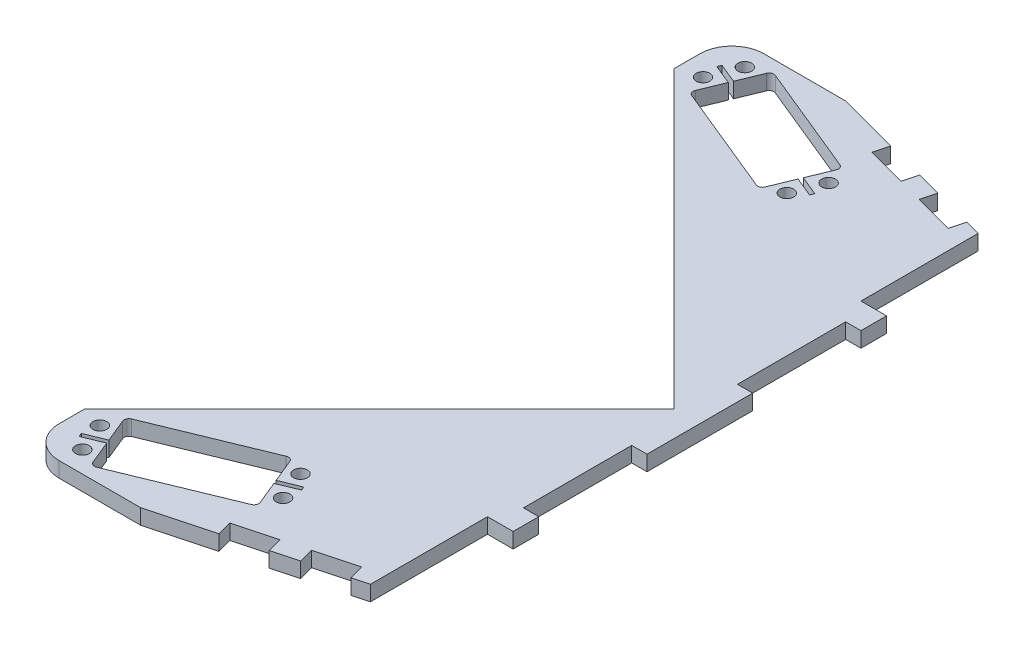
from build123d import *

# Parameters (mm, degrees)
SKETCH1_R           = 2.15
BOSS_EXTRUDE1_DEPTH = 4.7625
FILLET1_R           = 10
SKETCH2_W           = 4.7625
SKETCH2_H           = 33.783
CUT_EXTRUDE1_DEPTH  = 10


with BuildPart() as part:
    # Sketch1 → Boss-Extrude1 (new body)
    with BuildSketch(Plane(origin=(0, 0, 0), x_dir=(1, 0, 0), z_dir=(0, 1, 0))):
        Polygon((0, 0), (-92, 92), (-92, 110), (-56.601944845, 110), (0, 94.833554589), (0, 58.293), (8, 58.293), (8, -58.293), (0, -58.293), (0, -94.833554589), (-56.601944845, -110), (-92, -110), (-92, -92), align=None)
        with Locations((-85.159917522, 94.147890435)):
            Circle(SKETCH1_R, mode=Mode.SUBTRACT)
        with Locations((-81.358825255, 103.397306502)):
            Circle(SKETCH1_R, mode=Mode.SUBTRACT)
        with Locations((-36.961628134, 85.152063619)):
            Circle(SKETCH1_R, mode=Mode.SUBTRACT)
        with Locations((-40.762720402, 75.902647552)):
            Circle(SKETCH1_R, mode=Mode.SUBTRACT)
        with Locations((-40.762720402, -75.902647552)):
            Circle(SKETCH1_R, mode=Mode.SUBTRACT)
        with Locations((-36.961628134, -85.152063619)):
            Circle(SKETCH1_R, mode=Mode.SUBTRACT)
        with Locations((-81.358825255, -103.397306502)):
            Circle(SKETCH1_R, mode=Mode.SUBTRACT)
        with Locations((-85.159917522, -94.147890435)):
            Circle(SKETCH1_R, mode=Mode.SUBTRACT)
        with BuildLine():
            Line((-79.322036695, 97.830250065), (-76.328676535, 105.114165218))
            ThreePointArc((-76.328676535, 105.114165218), (-76.087243425, 105.511850251), (-75.735570504, 105.816431091))
            ThreePointArc((-75.735570504, 105.816431091), (-75.067221358, 106.038703614), (-74.371100284, 105.931413788))
            Line((-74.371100284, 105.931413788), (-40.148260837, 91.867372399))
            ThreePointArc((-40.148260837, 91.867372399), (-39.577853455, 91.454176231), (-39.258927152, 90.826178087))
            ThreePointArc((-39.258927152, 90.826178087), (-39.223044121, 90.362329254), (-39.331012268, 89.909796149))
            Line((-39.331012268, 89.909796149), (-42.324372428, 82.625880996))
            Line((-42.324372428, 82.625880996), (-36.219757824, 80.1171601))
            Line((-36.219757824, 80.1171601), (-36.694894357, 78.960983092))
            Line((-36.694894357, 78.960983092), (-42.799508961, 81.469703988))
            Line((-42.799508961, 81.469703988), (-45.792869122, 74.185788836))
            ThreePointArc((-45.792869122, 74.185788836), (-46.034302231, 73.788103802), (-46.385975153, 73.483522962))
            ThreePointArc((-46.385975153, 73.483522962), (-47.054324299, 73.261250439), (-47.750445372, 73.368540266))
            Line((-47.750445372, 73.368540266), (-81.973284819, 87.432581654))
            ThreePointArc((-81.973284819, 87.432581654), (-82.543692202, 87.845777823), (-82.862618505, 88.473775966))
            ThreePointArc((-82.862618505, 88.473775966), (-82.898501536, 88.937624799), (-82.790533389, 89.390157905))
            Line((-82.790533389, 89.390157905), (-79.797173228, 96.674073057))
            Line((-79.797173228, 96.674073057), (-85.901787832, 99.182793954))
            Line((-85.901787832, 99.182793954), (-85.426651299, 100.338970962))
            Line((-85.426651299, 100.338970962), (-79.322036695, 97.830250065))
        make_face(mode=Mode.SUBTRACT)
        with BuildLine():
            Line((-47.750445372, -73.368540266), (-81.973284819, -87.432581654))
            ThreePointArc((-81.973284819, -87.432581654), (-82.543692202, -87.845777823), (-82.862618505, -88.473775966))
            ThreePointArc((-82.862618505, -88.473775966), (-82.898501536, -88.937624799), (-82.790533389, -89.390157905))
            Line((-82.790533389, -89.390157905), (-79.797173228, -96.674073057))
            Line((-79.797173228, -96.674073057), (-85.901787832, -99.182793954))
            Line((-85.901787832, -99.182793954), (-85.426651299, -100.338970962))
            Line((-85.426651299, -100.338970962), (-79.322036695, -97.830250065))
            Line((-79.322036695, -97.830250065), (-76.328676535, -105.114165218))
            ThreePointArc((-76.328676535, -105.114165218), (-76.087243425, -105.511850251), (-75.735570504, -105.816431091))
            ThreePointArc((-75.735570504, -105.816431091), (-75.067221358, -106.038703614), (-74.371100284, -105.931413788))
            Line((-74.371100284, -105.931413788), (-40.148260837, -91.867372399))
            ThreePointArc((-40.148260837, -91.867372399), (-39.577853455, -91.454176231), (-39.258927152, -90.826178087))
            ThreePointArc((-39.258927152, -90.826178087), (-39.223044121, -90.362329254), (-39.331012268, -89.909796149))
            Line((-39.331012268, -89.909796149), (-42.324372428, -82.625880996))
            Line((-42.324372428, -82.625880996), (-36.219757824, -80.1171601))
            Line((-36.219757824, -80.1171601), (-36.694894357, -78.960983092))
            Line((-36.694894357, -78.960983092), (-42.799508961, -81.469703988))
            Line((-42.799508961, -81.469703988), (-45.792869122, -74.185788836))
            ThreePointArc((-45.792869122, -74.185788836), (-46.034302231, -73.788103802), (-46.385975153, -73.483522962))
            ThreePointArc((-46.385975153, -73.483522962), (-47.054324299, -73.261250439), (-47.750445372, -73.368540266))
        make_face(mode=Mode.SUBTRACT)
    extrude(amount=BOSS_EXTRUDE1_DEPTH)

    # Fillet1
    fillet1_edges = [part.edges().sort_by_distance(p)[0] for p in [
        (-92, 2.38125, 110),
        (-92, 2.38125, -110),
    ]]
    fillet(fillet1_edges, radius=FILLET1_R)

    # Sketch2 → Cut-Extrude1 (cut)
    with BuildSketch(Plane(origin=(0, 0, 0), x_dir=(1, 0, 0), z_dir=(0, 1, 0))):
        Polygon((-4.829629131, 96.127649814), (-17.19282542, 99.440358276), (-18.425451123, 94.840136528), (-6.062254834, 91.527428067), align=None)
        Polygon((-24.920232031, 101.510910637), (-37.283428319, 104.823619098), (-38.516054022, 100.22339735), (-26.152857733, 96.910688889), align=None)
        Polygon((-26.152857733, -96.910688889), (-38.516054022, -100.22339735), (-37.283428319, -104.823619098), (-24.920232031, -101.510910637), align=None)
        Polygon((-6.062254834, -91.527428067), (-18.425451123, -94.840136528), (-17.19282542, -99.440358276), (-4.829629131, -96.127649814), align=None)
        with Locations((5.61875, 33.4015)):
            Rectangle(SKETCH2_W, SKETCH2_H)
        with Locations((5.61875, -33.4015)):
            Rectangle(SKETCH2_W, SKETCH2_H)
    extrude(amount=CUT_EXTRUDE1_DEPTH, mode=Mode.SUBTRACT)


solid = part.part
